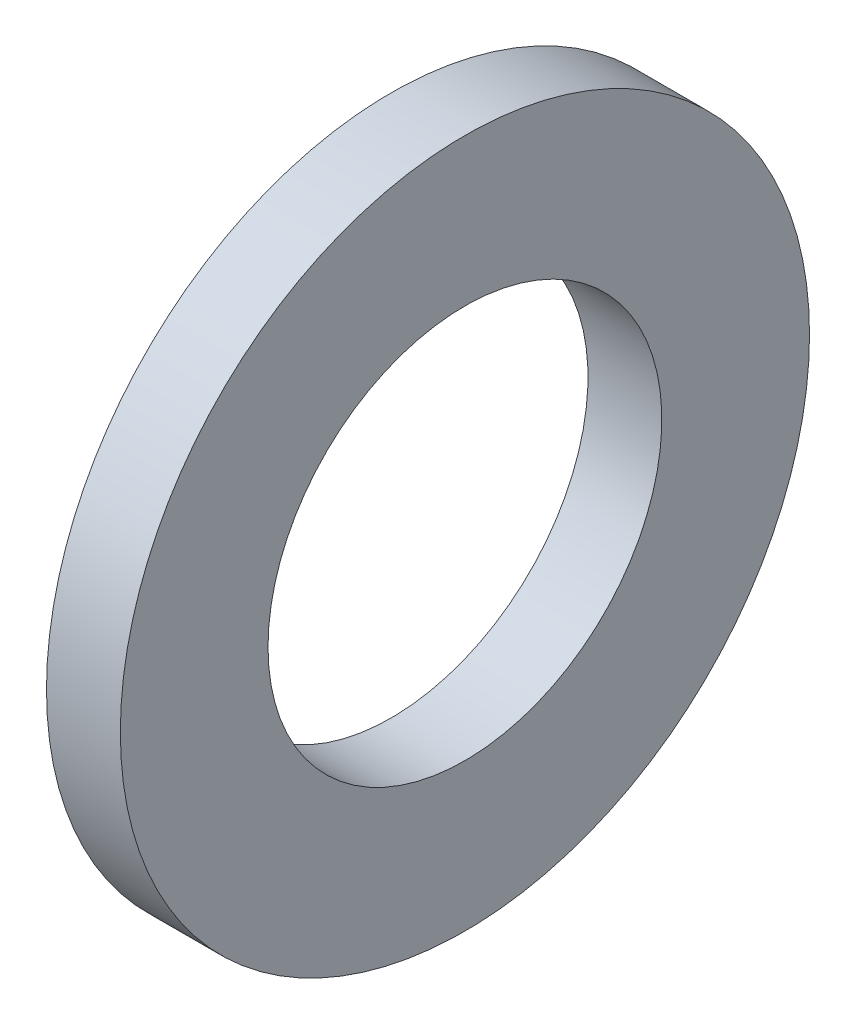
from build123d import *

# Parameters (mm, degrees)
ESQUISSE1_W = 1.5
ESQUISSE1_H = 3


with BuildPart() as part:
    # Esquisse1 → Révolution1 (revolve)
    with BuildSketch(Plane.XY, mode=Mode.PRIVATE) as r_volution1_sk:
        with Locations((-7.36298829, 33.395427868)):
            Rectangle(ESQUISSE1_W, ESQUISSE1_H)
    revolve(r_volution1_sk.sketch.rotate(Axis((-46.974058577, 27.895427868, 0), (1, 0, 0)), 90), axis=Axis((-46.974058577, 27.895427868, 0), (1, 0, 0)))  # turned: the seam where the file's is


solid = part.part
